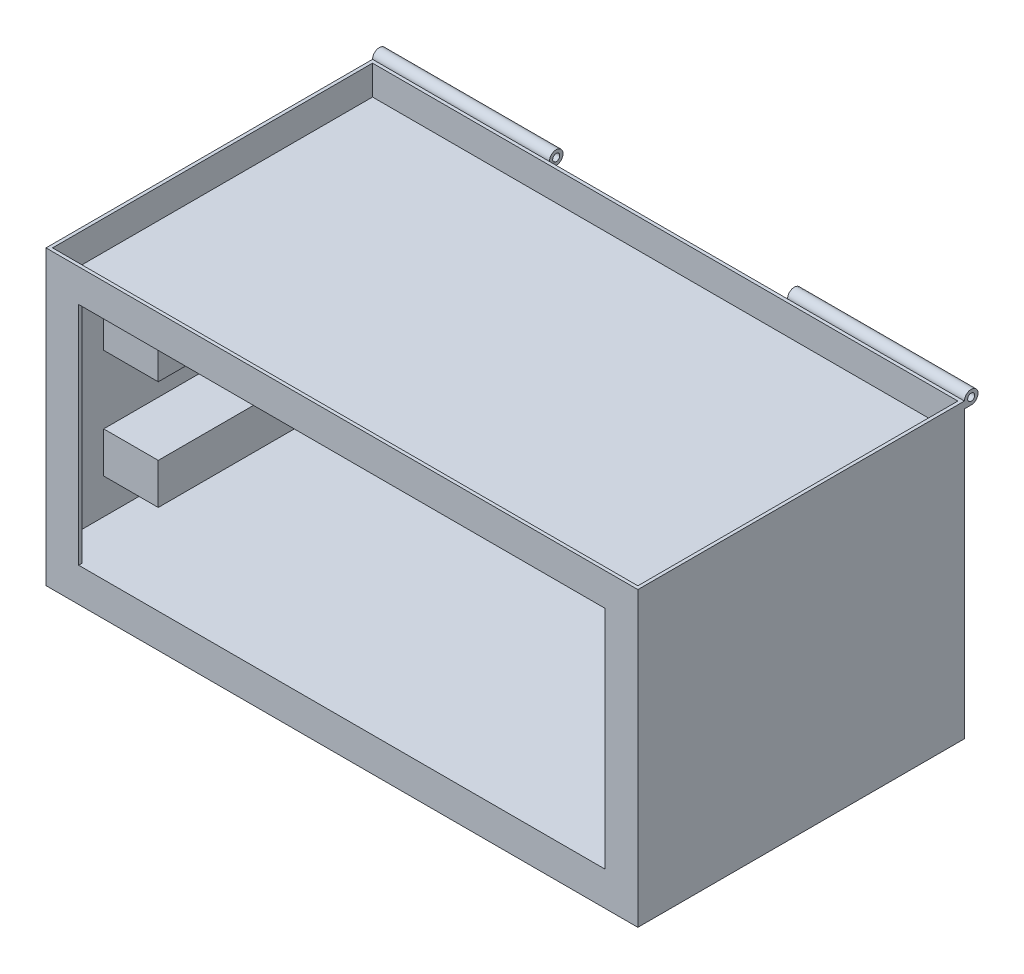
from build123d import *

# Parameters (mm, degrees)
SKETCH1_W               = 276.225
SKETCH1_H               = 152.4
BULK_EXTRUDE_DEPTH      = 136.525
SKETCH1_13_W            = 273.177
SKETCH1_13_H            = 149.352
SKETCH1_13_W_2          = 245.745
SKETCH1_13_H_2          = 1.524
INNER_SHELL_CUT_DEPTH   = 120.65
SKETCH1_14_W            = 245.745
SKETCH1_14_H            = 1.524
TOP_WALL_EXTRUDE_DEPTH  = 15.24
TOP_START               = -15.24
SKETCH1_15_W            = 273.177
SKETCH1_15_H            = 149.352
TOP_FLOOR_EXTRUDE_DEPTH = 1.524
SKETCH5_R               = 1.651
HINGE_EXTRUDE_DEPTH     = 82.55
SKETCH7_W               = 25.4635
SKETCH7_H               = 19.05
RAILS_EXTRUDE_DEPTH     = 125.476


with BuildPart() as part:
    # Sketch1 → Bulk-Extrude (new body)
    with BuildSketch(Plane(origin=(0, 0, 0), x_dir=(1, 0, 0), z_dir=(0, 1, 0))):
        with Locations((136.5885, 74.676)):
            Rectangle(SKETCH1_W, SKETCH1_H)
    extrude(amount=-BULK_EXTRUDE_DEPTH)

    # Sketch1_13 → Inner Shell-Cut (cut)
    with BuildSketch(Plane(origin=(0, 0, 0), x_dir=(1, 0, 0), z_dir=(0, 1, 0))):
        with Locations((136.5885, 74.676)):
            Rectangle(SKETCH1_13_W, SKETCH1_13_H)
        with Locations((136.5885, -0.762)):
            Rectangle(SKETCH1_13_W_2, SKETCH1_13_H_2)
    extrude(amount=-INNER_SHELL_CUT_DEPTH, mode=Mode.SUBTRACT)

    # Sketch1_14 → Top Wall-Extrude (add)
    with BuildSketch(Plane(origin=(0, 0, 0), x_dir=(1, 0, 0), z_dir=(0, 1, 0))):
        with Locations((136.5885, -0.762)):
            Rectangle(SKETCH1_14_W, SKETCH1_14_H)
    extrude(amount=-TOP_WALL_EXTRUDE_DEPTH)

    # Sketch1_15 → Top Floor-Extrude (add)
    with BuildSketch(Plane(origin=(0, 0, 0), x_dir=(1, 0, 0), z_dir=(0, 1, 0)).offset(TOP_START)):
        with Locations((136.5885, 74.676)):
            Rectangle(SKETCH1_15_W, SKETCH1_15_H)
    extrude(amount=TOP_FLOOR_EXTRUDE_DEPTH)

    # Sketch5 → Hinge-Extrude (add)
    with BuildSketch(Plane(origin=(274.701, 0, 0), x_dir=(0, 0, -1), z_dir=(1, 0, 0))):
        with BuildLine():
            Line((150.876, 0), (150.876, -3.175))
            Line((150.876, -3.175), (154.051, -3.175))
            ThreePointArc((154.051, -3.175), (156.29606403, 2.24506403), (150.876, 0))
        make_face()
        with Locations((154.051, 0)):
            Circle(SKETCH5_R, mode=Mode.SUBTRACT)
    hinge_extrude = extrude(amount=-HINGE_EXTRUDE_DEPTH)

    # Mirror1: Hinge-Extrude across plane
    add(hinge_extrude.mirror(Plane(origin=(136.5885, 0, 0), x_dir=(0, 0, 1), z_dir=(1, 0, 0))))

    # Sketch7 → Rails-Extrude (add)
    with BuildSketch(Plane.XY.offset(-149.352)):
        with Locations((12.73175, -43.815)):
            Rectangle(SKETCH7_W, SKETCH7_H)
        with Locations((260.44525, -43.815)):
            Rectangle(SKETCH7_W, SKETCH7_H)
        with Locations((12.73175, -94.615)):
            Rectangle(SKETCH7_W, SKETCH7_H)
        with Locations((260.44525, -94.615)):
            Rectangle(SKETCH7_W, SKETCH7_H)
    extrude(amount=RAILS_EXTRUDE_DEPTH)


solid = part.part
